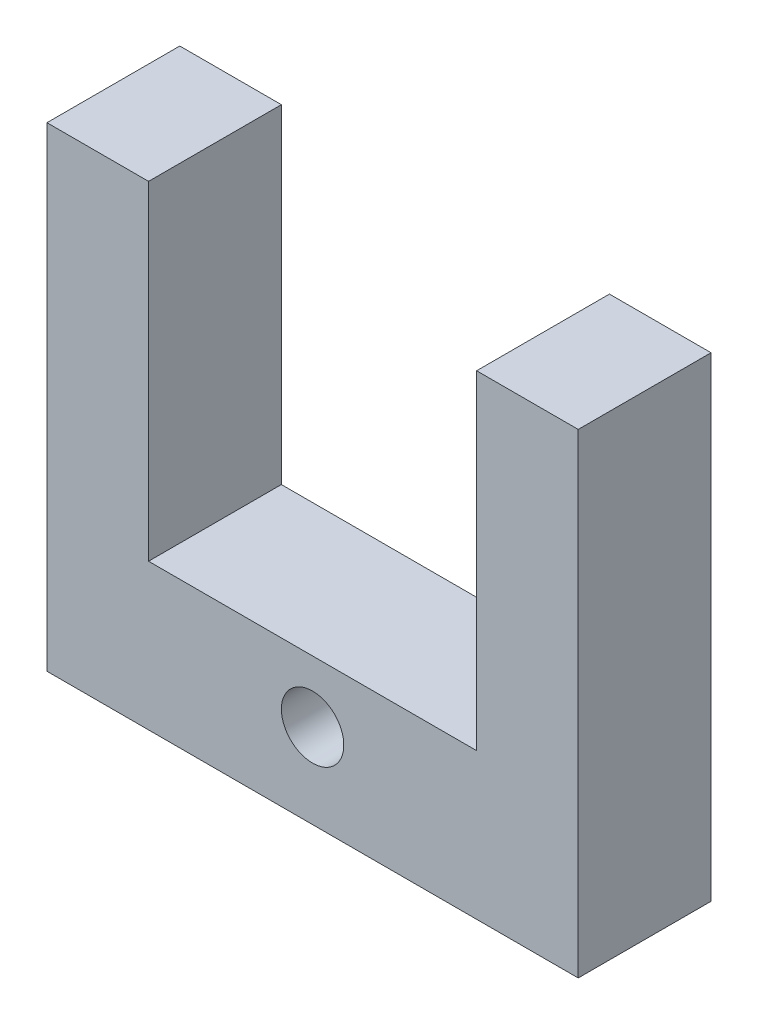
from build123d import *

# Parameters (mm, degrees)
SKETCH3_W           = 20
SKETCH3_H           = 70
BOSS_EXTRUDE3_DEPTH = 5
CUT_EXTRUDE2_DEPTH  = 2
SKETCH6_R           = 3.57
CUT_EXTRUDE3_DEPTH  = 3
SKETCH7_R           = 1.175
SKETCH7_W           = 12.35
SKETCH7_H           = 23
CUT_EXTRUDE4_DEPTH  = 5
SKETCH8_W           = 1.25
SKETCH8_H           = 25
CUT_EXTRUDE5_DEPTH  = 30
SKETCH10_R          = 1.175
CUT_EXTRUDE8_DEPTH  = 10


with BuildPart() as part:
    # Sketch3 → Boss-Extrude3 (new body)
    with BuildSketch(Plane.XY):
        Rectangle(SKETCH3_W, SKETCH3_H)
    extrude(amount=BOSS_EXTRUDE3_DEPTH)

    # Sketch4 → Cut-Extrude2 (cut)
    with BuildSketch(Plane.XY.offset(5)):
        with BuildLine():
            Line((-2.85, 24.850023256), (-1.875, 12.739206809))
            Line((-1.875, 12.739206809), (1.875, 12.739206809))
            Line((1.875, 12.739206809), (2.85, 24.850023256))
            ThreePointArc((2.85, 24.850023256), (0, 23.43), (-2.85, 24.850023256))
        make_face()
        with BuildLine():
            Line((1.875, 12.739206809), (-1.875, 12.739206809))
            ThreePointArc((-1.875, 12.739206809), (0, 10.864206809), (1.875, 12.739206809))
        make_face()
        with BuildLine():
            ThreePointArc((3.57, 27), (-1.133666618, 30.385217866), (-2.85, 24.850023256))
            Line((-2.85, 24.850023256), (2.85, 24.850023256))
            ThreePointArc((2.85, 24.850023256), (3.385217866, 25.866333382), (3.57, 27))
        make_face()
        with BuildLine():
            Line((2.85, 24.850023256), (-2.85, 24.850023256))
            ThreePointArc((-2.85, 24.850023256), (0, 23.43), (2.85, 24.850023256))
        make_face()
    extrude(amount=-CUT_EXTRUDE2_DEPTH, mode=Mode.SUBTRACT)

    # Sketch6 → Cut-Extrude3 (cut)
    with BuildSketch(Plane.XY.offset(3)):
        with Locations((0, 27)):
            Circle(SKETCH6_R)
    extrude(amount=-CUT_EXTRUDE3_DEPTH, mode=Mode.SUBTRACT)

    # Sketch7 → Cut-Extrude4 (cut)
    with BuildSketch(Plane.XY.offset(5)):
        with Locations((0, -4.18)):
            Circle(SKETCH7_R)
        with Locations((0, -31.82)):
            Circle(SKETCH7_R)
        with Locations((0, -18)):
            Rectangle(SKETCH7_W, SKETCH7_H)
    extrude(amount=-CUT_EXTRUDE4_DEPTH, mode=Mode.SUBTRACT)

    # Sketch8 → Cut-Extrude5 (cut)
    with BuildSketch(Plane(origin=(10, 0, 0), x_dir=(0, 0, -1), z_dir=(1, 0, 0))):
        with Locations((-0.625, 22.5)):
            Rectangle(SKETCH8_W, SKETCH8_H)
    extrude(amount=-CUT_EXTRUDE5_DEPTH, mode=Mode.SUBTRACT)

    # Sketch10 → Cut-Extrude8 (cut)
    with BuildSketch(Plane.XY.offset(5)):
        Polygon((-10, 35), (-10, -17.114677165), (-6.175, -17.114677165), (-6.175, -6.5), (6.175, -6.5), (6.175, -17.114677165), (10, -17.114677165), (10, 35), align=None)
        with Locations((0, -4.18)):
            Circle(SKETCH10_R, mode=Mode.SUBTRACT)
        with BuildLine():
            Line((2.85, 24.850023256), (1.875, 12.739206809))
            ThreePointArc((1.875, 12.739206809), (0, 10.864206809), (-1.875, 12.739206809))
            Line((-1.875, 12.739206809), (-2.85, 24.850023256))
            ThreePointArc((-2.85, 24.850023256), (0, 30.57), (2.85, 24.850023256))
        make_face(mode=Mode.SUBTRACT)
        with BuildLine():
            ThreePointArc((1.875, 12.739206809), (0, 10.864206809), (-1.875, 12.739206809))
            Line((-1.875, 12.739206809), (-2.85, 24.850023256))
            ThreePointArc((-2.85, 24.850023256), (0, 30.57), (2.85, 24.850023256))
            Line((2.85, 24.850023256), (1.875, 12.739206809))
        make_face()
    extrude(amount=-CUT_EXTRUDE8_DEPTH, mode=Mode.SUBTRACT)


solid = part.part
